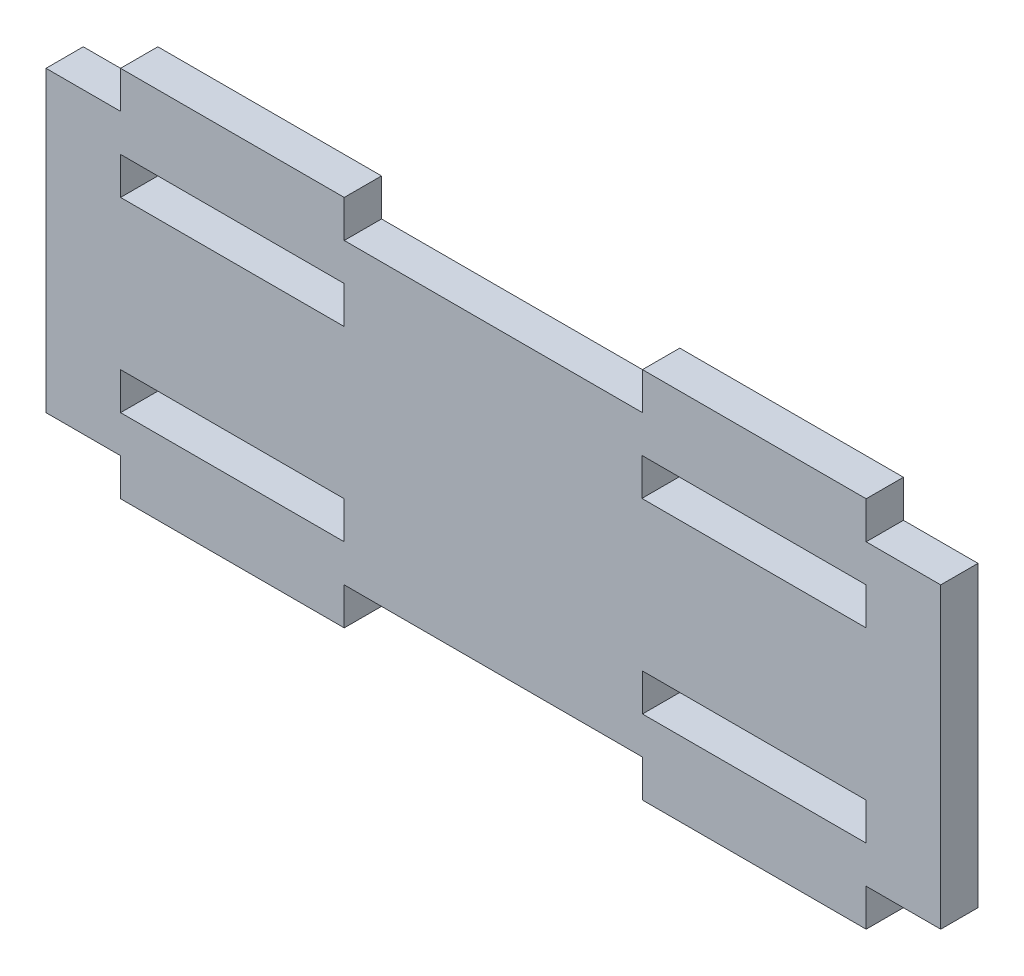
from build123d import *

# Parameters (mm, degrees)
SKETCH1_W           = 120
SKETCH1_H           = 40
SKETCH1_W_2         = 30.073092916
SKETCH1_H_2         = 5
SKETCH1_W_3         = 30
BOSS_EXTRUDE1_DEPTH = 5


with BuildPart() as part:
    # Sketch1 → Boss-Extrude1 (new body)
    with BuildSketch(Plane.XY):
        Rectangle(SKETCH1_W, SKETCH1_H)
        with Locations((34.956464204, 12.5)):
            Rectangle(SKETCH1_W_2, SKETCH1_H_2, mode=Mode.SUBTRACT)
        with Locations((-35, 12.5)):
            Rectangle(SKETCH1_W_3, SKETCH1_H_2, mode=Mode.SUBTRACT)
        with Locations((-35, -12.5)):
            Rectangle(SKETCH1_W_3, SKETCH1_H_2, mode=Mode.SUBTRACT)
        with Locations((35, -12.5)):
            Rectangle(SKETCH1_W_3, SKETCH1_H_2, mode=Mode.SUBTRACT)
        with Locations((-35, -22.5)):
            Rectangle(SKETCH1_W_3, SKETCH1_H_2)
        with Locations((35, -22.5)):
            Rectangle(SKETCH1_W_3, SKETCH1_H_2)
        with Locations((35, 22.5)):
            Rectangle(SKETCH1_W_3, SKETCH1_H_2)
        with Locations((-35, 22.5)):
            Rectangle(SKETCH1_W_3, SKETCH1_H_2)
    extrude(amount=BOSS_EXTRUDE1_DEPTH)


solid = part.part
